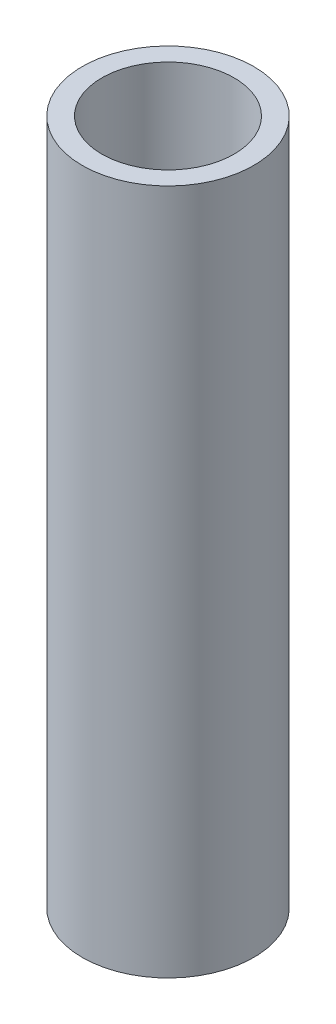
from build123d import *

# Parameters (mm, degrees)
SKETCH1_R           = 8.75
SKETCH1_R_2         = 6.75
BOSS_EXTRUDE1_DEPTH = 70


with BuildPart() as part:
    # Sketch1 → Boss-Extrude1 (new body)
    with BuildSketch(Plane(origin=(0, 0, 0), x_dir=(1, 0, 0), z_dir=(0, 1, 0))):
        Circle(SKETCH1_R)
        Circle(SKETCH1_R_2, mode=Mode.SUBTRACT)
    extrude(amount=BOSS_EXTRUDE1_DEPTH)


solid = part.part
